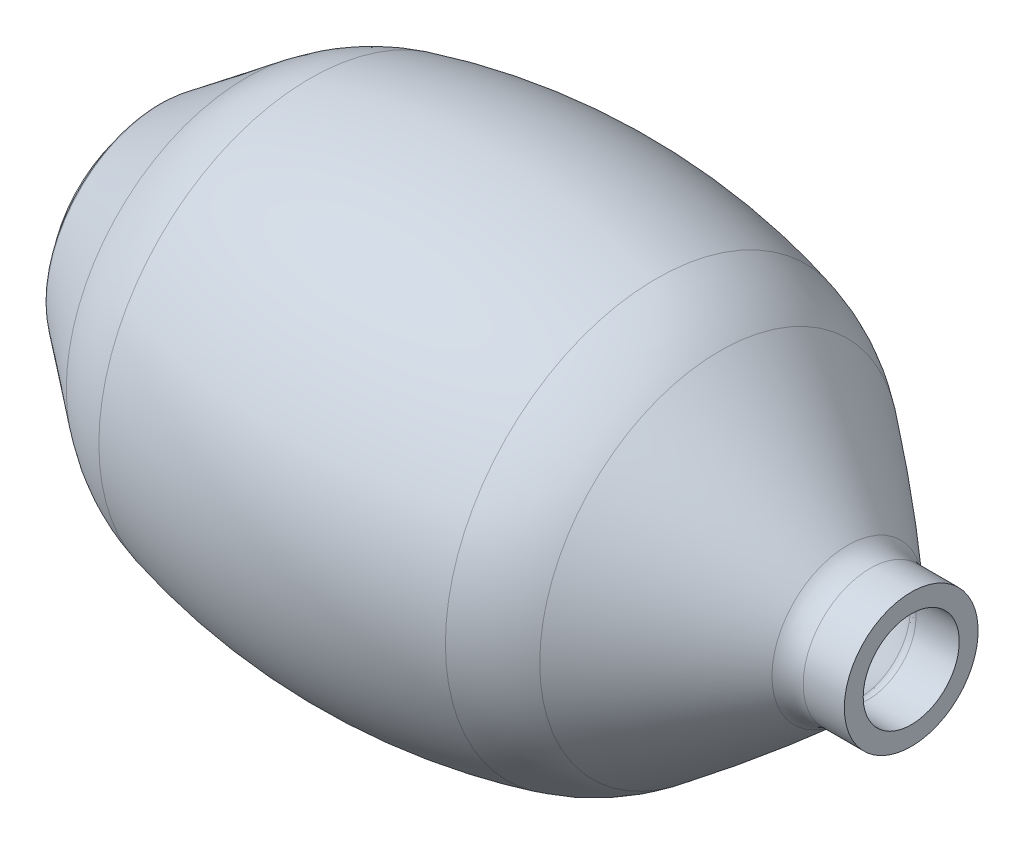
from build123d import *


with BuildPart() as part:
    # Sketch1 → Revolve1 (revolve)
    with BuildSketch(Plane(origin=(0, 0, 0), x_dir=(1, 0, 0), z_dir=(0, 1, 0))):
        with BuildLine():
            Line((-69, 52.5), (-93.653848, 33.700656198))
            ThreePointArc((-93.653848, 33.700656198), (-94.813224268, 32.294470097), (-95.228413353, 30.519891074))
            Line((-95.228413353, 30.519891074), (-95.228413353, 28))
            Line((-95.228413353, 28), (-98.228413353, 28))
            Line((-98.228413353, 28), (-98.228413353, 25.5))
            Line((-98.228413353, 25.5), (-92.228413353, 25.5))
            Line((-92.228413353, 25.5), (-92.228413353, 30.519891074))
            ThreePointArc((-92.228413353, 30.519891074), (-92.124616082, 30.96353583), (-91.834772015, 31.315082355))
            Line((-91.834772015, 31.315082355), (-67.180924015, 50.114426157))
            ThreePointArc((-67.180924015, 50.114426157), (-66.914566676, 50.421389231), (-66.792358074, 50.808994208))
            ThreePointArc((-66.792358074, 50.808994208), (-66.525255026, 51.623693453), (-65.941563391, 52.251692636))
            ThreePointArc((-65.941563391, 52.251692636), (-59.323608703, 56.123529001), (-52.192451771, 58.940449641))
            ThreePointArc((-52.192451771, 58.940449641), (-51.338079255, 59.012049234), (-50.532230419, 58.719326581))
            ThreePointArc((-50.532230419, 58.719326581), (-50.151841866, 58.576228328), (-49.745924422, 58.596317851))
            ThreePointArc((-49.745924422, 58.596317851), (0, 64.950350095), (49.745924422, 58.596317851))
            ThreePointArc((49.745924422, 58.596317851), (50.151841866, 58.576228328), (50.532230419, 58.719326581))
            ThreePointArc((50.532230419, 58.719326581), (51.338079255, 59.012049234), (52.192451771, 58.940449641))
            ThreePointArc((52.192451771, 58.940449641), (59.323608703, 56.123529001), (65.941563391, 52.251692636))
            ThreePointArc((65.941563391, 52.251692636), (66.525255026, 51.623693453), (66.792358074, 50.808994208))
            ThreePointArc((66.792358074, 50.808994208), (66.914566676, 50.421389231), (67.180924015, 50.114426157))
            ThreePointArc((67.180924015, 50.114426157), (88.69644056, 33.002781854), (109.495902182, 15.027570612))
            ThreePointArc((109.495902182, 15.027570612), (110.739014719, 14.265718439), (112.172591094, 14))
            Line((112.172591094, 14), (124.771586647, 14))
            Line((124.771586647, 14), (124.771586647, 19.5))
            Line((124.771586647, 19.5), (112.794503003, 19.5))
            ThreePointArc((112.794503003, 19.5), (109.25978401, 20.145548565), (106.181431573, 21.998847671))
            ThreePointArc((106.181431573, 21.998847671), (87.861772457, 37.579846599), (69, 52.5))
            ThreePointArc((69, 52.5), (60.198540141, 57.921999179), (50.5, 61.5))
            ThreePointArc((50.5, 61.5), (0, 67.950350095), (-50.5, 61.5))
            ThreePointArc((-50.5, 61.5), (-60.198540141, 57.921999179), (-69, 52.5))
        make_face()
    revolve(axis=Axis((0, 0, 0), (1, 0, 0)))


solid = part.part
